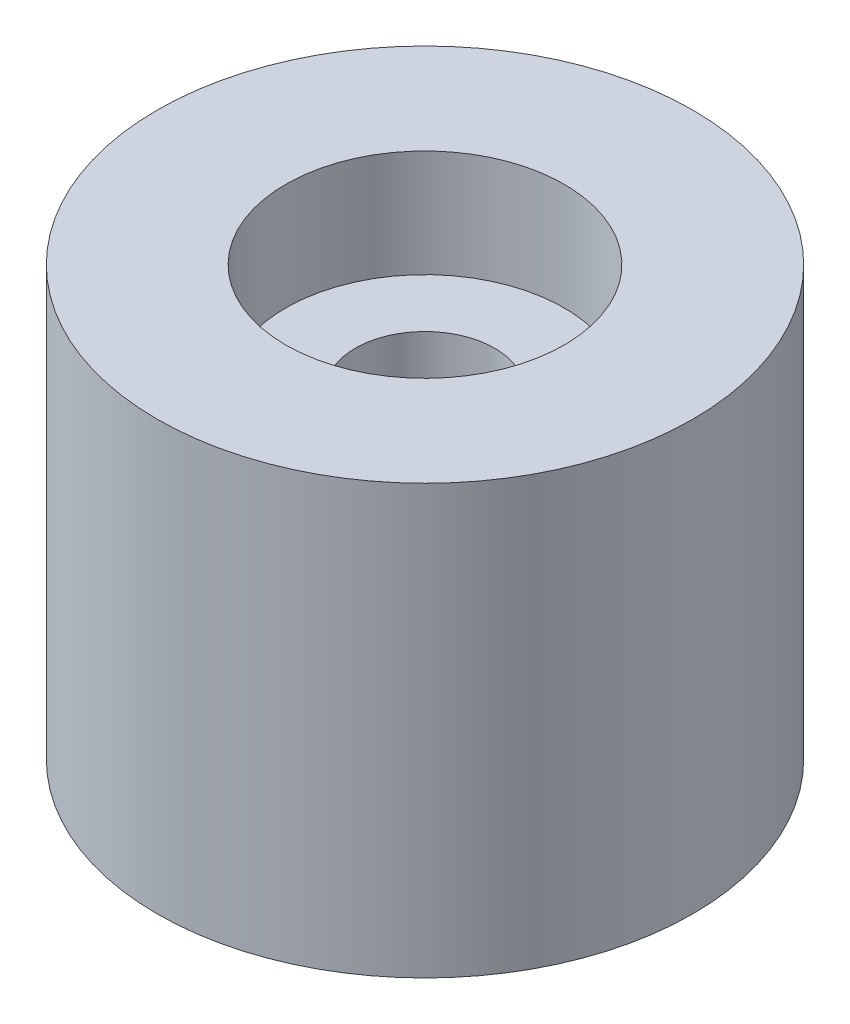
from build123d import *

# Parameters (mm, degrees)
SKETCH1_R           = 12.5
SKETCH1_R_2         = 3.25
BOSS_EXTRUDE1_DEPTH = 20
SKETCH2_R           = 6.5
CUT_EXTRUDE1_DEPTH  = 5
SKETCH3_R           = 6.5
CUT_EXTRUDE2_DEPTH  = 5


with BuildPart() as part:
    # Sketch1 → Boss-Extrude1 (new body)
    with BuildSketch(Plane(origin=(0, 0, 0), x_dir=(1, 0, 0), z_dir=(0, 1, 0))):
        Circle(SKETCH1_R)
        Circle(SKETCH1_R_2, mode=Mode.SUBTRACT)
    extrude(amount=BOSS_EXTRUDE1_DEPTH)

    # Sketch2 → Cut-Extrude1 (cut)
    with BuildSketch(Plane(origin=(0, 0, 0), x_dir=(1, 0, 0), z_dir=(0, 1, 0))):
        Circle(SKETCH2_R)
    extrude(amount=CUT_EXTRUDE1_DEPTH, mode=Mode.SUBTRACT)

    # Sketch3 → Cut-Extrude2 (cut)
    with BuildSketch(Plane(origin=(0, 20, 0), x_dir=(1, 0, 0), z_dir=(0, 1, 0))):
        Circle(SKETCH3_R)
    extrude(amount=-CUT_EXTRUDE2_DEPTH, mode=Mode.SUBTRACT)


solid = part.part
